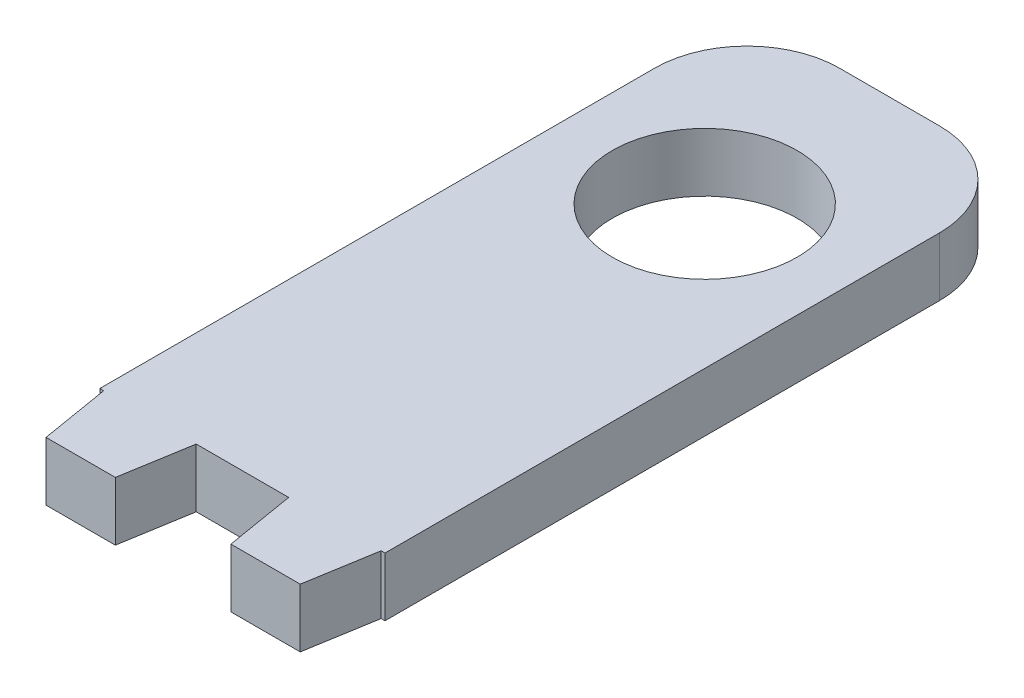
from build123d import *

# Parameters (mm, degrees)
SKETCH1_W           = 30.83672877
SKETCH1_H           = 70
SKETCH1_R           = 10
BOSS_EXTRUDE1_DEPTH = 6.35
FILLET1_R           = 10


with BuildPart() as part:
    # Sketch1 → Boss-Extrude1 (new body)
    with BuildSketch(Plane(origin=(0, 0, 0), x_dir=(1, 0, 0), z_dir=(0, 1, 0))):
        Polygon((13.75, -42.5), (15, -35), (5, -35), (6.25, -42.5), align=None)
        Polygon((-5, -35), (-15, -35), (-13.75, -42.5), (-6.25, -42.5), align=None)
        Rectangle(SKETCH1_W, SKETCH1_H)
        with Locations((0, 15)):
            Circle(SKETCH1_R, mode=Mode.SUBTRACT)
    extrude(amount=BOSS_EXTRUDE1_DEPTH)

    # Fillet1
    fillet1_edges = [part.edges().sort_by_distance(p)[0] for p in [
        (-15.418364385, 3.175, -35),
        (15.418364385, 3.175, -35),
    ]]
    fillet(fillet1_edges, radius=FILLET1_R)


solid = part.part
